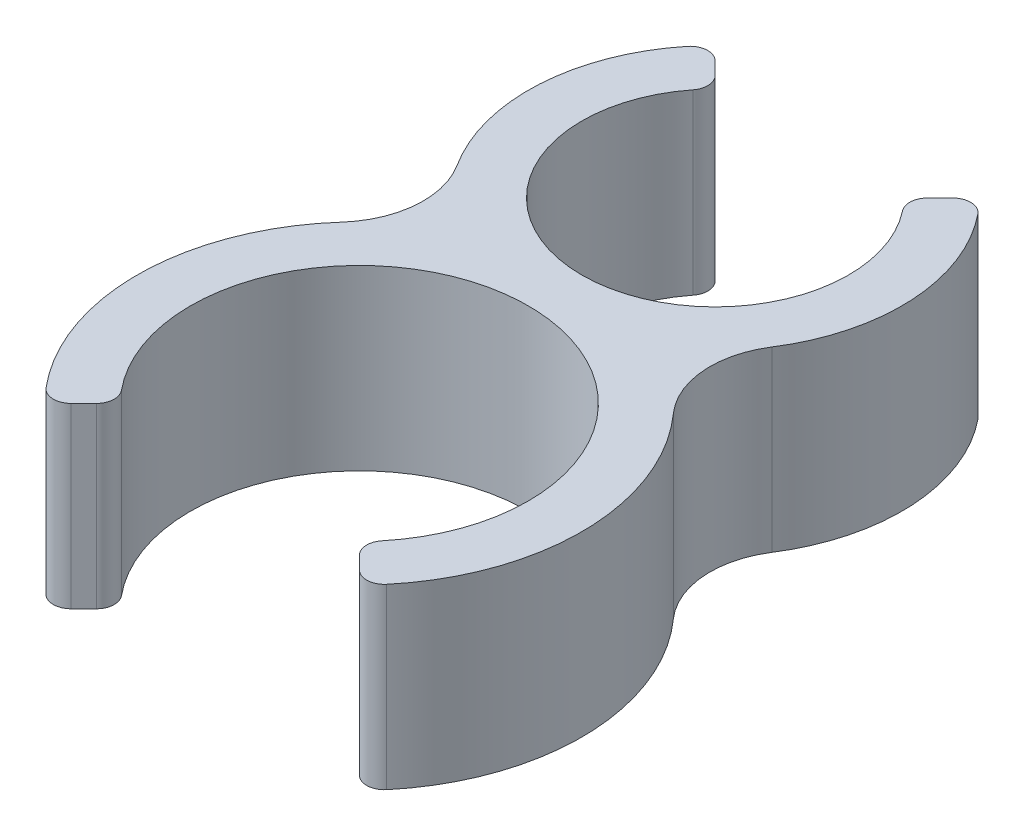
from build123d import *

# Parameters (mm, degrees)
BOSS_EXTRUDE1_DEPTH = 10
FILLET1_R           = 1
FILLET2_R           = 5


with BuildPart() as part:
    # Sketch1 → Boss-Extrude1 (new body)
    with BuildSketch(Plane(origin=(0, 0, 0), x_dir=(1, 0, 0), z_dir=(0, 1, 0))):
        with BuildLine():
            Line((-5.303300859, 15.303300859), (-7.424621202, 17.424621202))
            ThreePointArc((-7.424621202, 17.424621202), (-10.438158184, 8.862083601), (-5.650442461, 1.15))
            ThreePointArc((-5.650442461, 1.15), (-12.343952667, -8.031032616), (-8.838834765, -18.838834765))
            Line((-8.838834765, -18.838834765), (-6.717514421, -16.717514421))
            ThreePointArc((-6.717514421, -16.717514421), (0, -0.5), (6.717514421, -16.717514421))
            Line((6.717514421, -16.717514421), (8.838834765, -18.838834765))
            ThreePointArc((8.838834765, -18.838834765), (12.343952667, -8.031032616), (5.650442461, 1.15))
            ThreePointArc((5.650442461, 1.15), (10.438158184, 8.862083601), (7.424621202, 17.424621202))
            Line((7.424621202, 17.424621202), (5.303300859, 15.303300859))
            ThreePointArc((5.303300859, 15.303300859), (0, 2.5), (-5.303300859, 15.303300859))
        make_face()
    extrude(amount=BOSS_EXTRUDE1_DEPTH)

    # Fillet1
    fillet1_edges = [part.edges().sort_by_distance(p)[0] for p in [
        (5.303300859, 5, -15.303300859),
        (7.424621202, 5, -17.424621202),
        (8.838834765, 5, 18.838834765),
        (6.717514421, 5, 16.717514421),
        (-6.717514421, 5, 16.717514421),
        (-8.838834765, 5, 18.838834765),
        (-7.424621202, 5, -17.424621202),
        (-5.303300859, 5, -15.303300859),
    ]]
    fillet(fillet1_edges, radius=FILLET1_R)

    # Fillet2
    fillet2_edges = [part.edges().sort_by_distance(p)[0] for p in [
        (5.650442461, 5, -1.15),
        (-5.650442461, 5, -1.15),
    ]]
    fillet(fillet2_edges, radius=FILLET2_R)


solid = part.part
